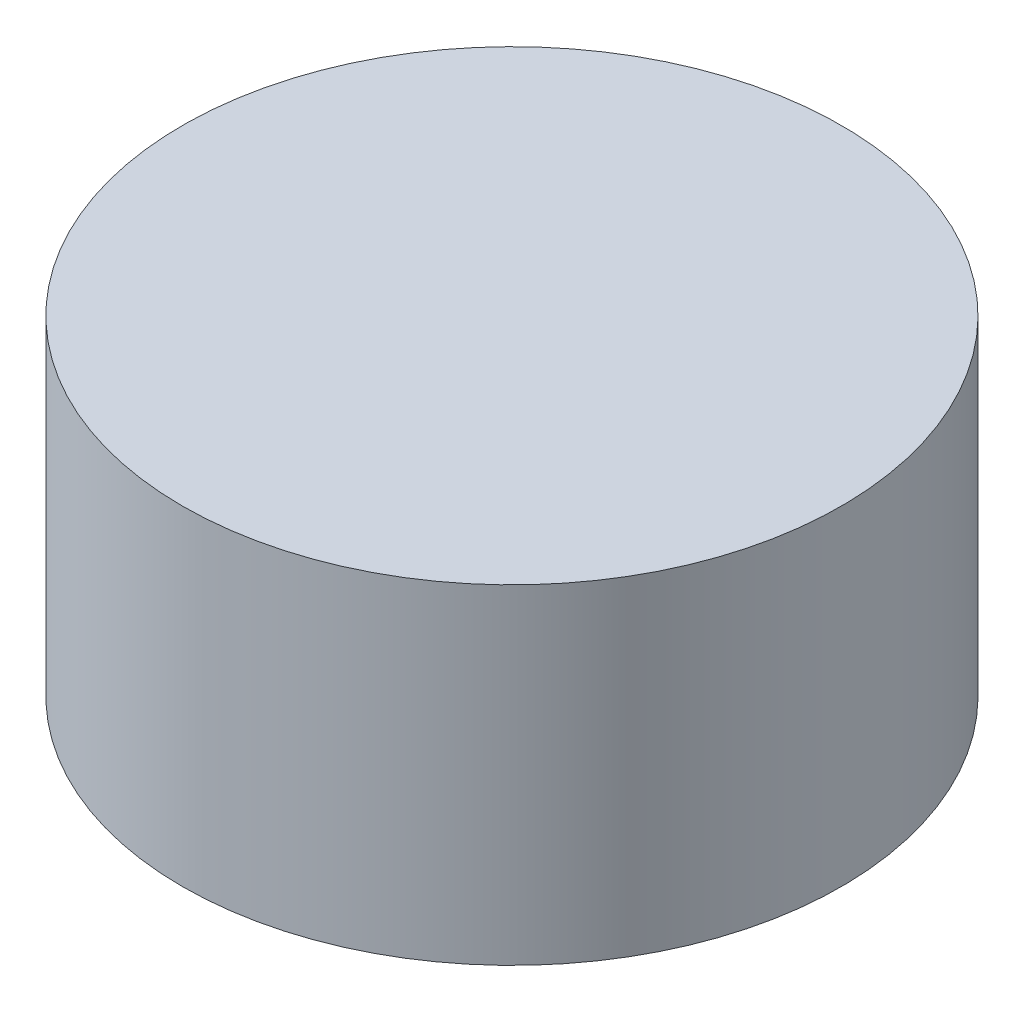
from build123d import *

# Parameters (mm, degrees)
SKETCH1_R           = 3.175
BOSS_EXTRUDE1_DEPTH = 1.5875


with BuildPart() as part:
    # Sketch1 → Boss-Extrude1 (new body, symmetric)
    with BuildSketch(Plane(origin=(0, 0, 0), x_dir=(1, 0, 0), z_dir=(0, 1, 0))):
        Circle(SKETCH1_R)
    extrude(amount=BOSS_EXTRUDE1_DEPTH, both=True)


solid = part.part
